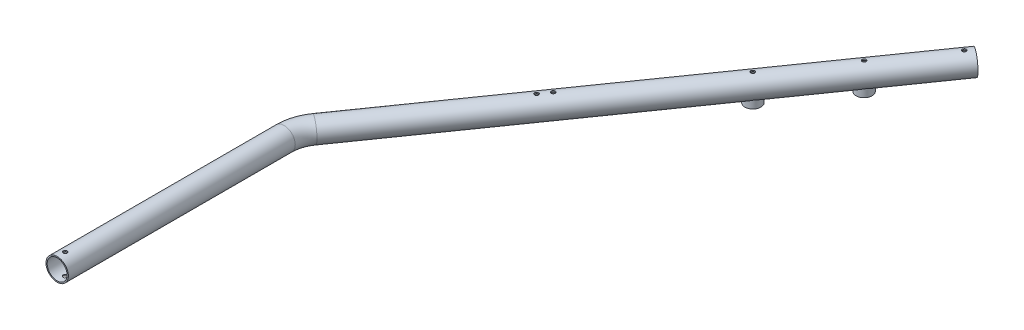
from build123d import *

# Parameters (mm, degrees)
SKETCH3_R                = 14
BOSS_EXTRUDE2_REACH      = 881.556
BOSS_EXTRUDE2_END_RADIUS = 14
SKETCH7_R                = 10
SKETCH5_R                = 12.5
CUT_EXTRUDE1_DEPTH       = 880.133806697
CUT_EXTRUDE1_DEPTH_BACK  = 880.133806697
SKETCH4_R                = 2.5
CUT_EXTRUDE2_DEPTH       = 880.133806788
CUT_EXTRUDE2_DEPTH_BACK  = 880.133806788
SKETCH9_R                = 2.5


with BuildPart() as part:
    # Sweep1: sweep along a path in Sketch2
    with BuildLine(Plane(origin=(0, 0, 0), x_dir=(1, 0, 0), z_dir=(0, 1, 0))) as sweep1_path:
        Line((0, 0), (-340.961596026, -487.087994323))
        ThreePointArc((-340.961596026, -487.087994323), (-347.686894433, -500.729142297), (-350, -515.761111541))
        Line((-350, -515.761111541), (-350, -800))
    # Sketch3 → Sweep1 (sweep)
    with BuildSketch(Plane.XY.offset(800)):
        with Locations((-350, 0)):
            Circle(SKETCH3_R)
    sweep(path=sweep1_path.line)

    # Boss-Extrude2: up to this cylinder (the profile starts outside it)
    boss_extrude2_end = Plane(origin=(-86.019351567, 0, 122.884787953), z_dir=(-0.5734623443633283, 0, 0.8192319205190406)) * Cylinder(BOSS_EXTRUDE2_END_RADIUS, 1892.112000281, mode=Mode.PRIVATE)
    # Sketch7 → Boss-Extrude2 (add, up to the surface)
    with BuildSketch(Plane(origin=(0, -19.5, 0), x_dir=(1, 0, 0), z_dir=(0, 1, 0)), mode=Mode.PRIVATE) as boss_extrude2_sk1:
        with Locations((-57.346234436, -81.923192052)):
            Circle(SKETCH7_R)
    boss_extrude2_tool1 = extrude(boss_extrude2_sk1.sketch, amount=BOSS_EXTRUDE2_REACH, mode=Mode.PRIVATE) - boss_extrude2_end
    add(boss_extrude2_tool1.solids().sort_by_distance((-57.346234, -19.5, 81.923192))[0])
    # Sketch7 → Boss-Extrude2 (add, up to the surface)
    with BuildSketch(Plane(origin=(0, -19.5, 0), x_dir=(1, 0, 0), z_dir=(0, 1, 0)), mode=Mode.PRIVATE) as boss_extrude2_sk2:
        with Locations((-114.692468873, -163.846384104)):
            Circle(SKETCH7_R)
    boss_extrude2_tool2 = extrude(boss_extrude2_sk2.sketch, amount=BOSS_EXTRUDE2_REACH, mode=Mode.PRIVATE) - boss_extrude2_end
    add(boss_extrude2_tool2.solids().sort_by_distance((-114.692469, -19.5, 163.846384))[0])

    # Cut-Sweep1: sweep along a path in Sketch2_2
    with BuildLine(Plane(origin=(0, 0, 0), x_dir=(1, 0, 0), z_dir=(0, 1, 0))) as cut_sweep1_path:
        Line((0, 0), (-340.961596026, -487.087994323))
        ThreePointArc((-340.961596026, -487.087994323), (-347.686894433, -500.729142297), (-350, -515.761111541))
        Line((-350, -515.761111541), (-350, -800))
    # Sketch5 → Cut-Sweep1 (sweep, cut)
    with BuildSketch(Plane.XY.offset(800)):
        with Locations((-350, 0)):
            Circle(SKETCH5_R)
    sweep(path=cut_sweep1_path.line, mode=Mode.SUBTRACT)

    # Sketch4 → Cut-Extrude1 (cut, two sides: drawn at the far end of the back side and taken through both)
    with BuildSketch(Plane(origin=(0, 0, 0), x_dir=(1, 0, 0), z_dir=(0, 1, 0)).offset(-CUT_EXTRUDE1_DEPTH_BACK)):
        with Locations((-5.734623444, -8.192319205)):
            Circle(SKETCH4_R)
        with Locations((-57.346234436, -81.923192052)):
            Circle(SKETCH4_R)
        with Locations((-114.692468873, -163.846384104)):
            Circle(SKETCH4_R)
        with Locations((-350, -790)):
            Circle(SKETCH4_R)
    extrude(amount=CUT_EXTRUDE1_DEPTH + CUT_EXTRUDE1_DEPTH_BACK, mode=Mode.SUBTRACT)

    # Sketch9 → Cut-Extrude2 (cut, two sides: drawn at the far end of the back side and taken through both)
    with BuildSketch(Plane(origin=(0, 0, 0), x_dir=(1, 0, 0), z_dir=(0, 1, 0)).offset(-CUT_EXTRUDE2_DEPTH_BACK)):
        with Locations((-217.667191988, -310.953131411)):
            Circle(SKETCH9_R)
        with Locations((-226.269127153, -323.241610219)):
            Circle(SKETCH9_R)
    extrude(amount=CUT_EXTRUDE2_DEPTH + CUT_EXTRUDE2_DEPTH_BACK, mode=Mode.SUBTRACT)


solid = part.part
